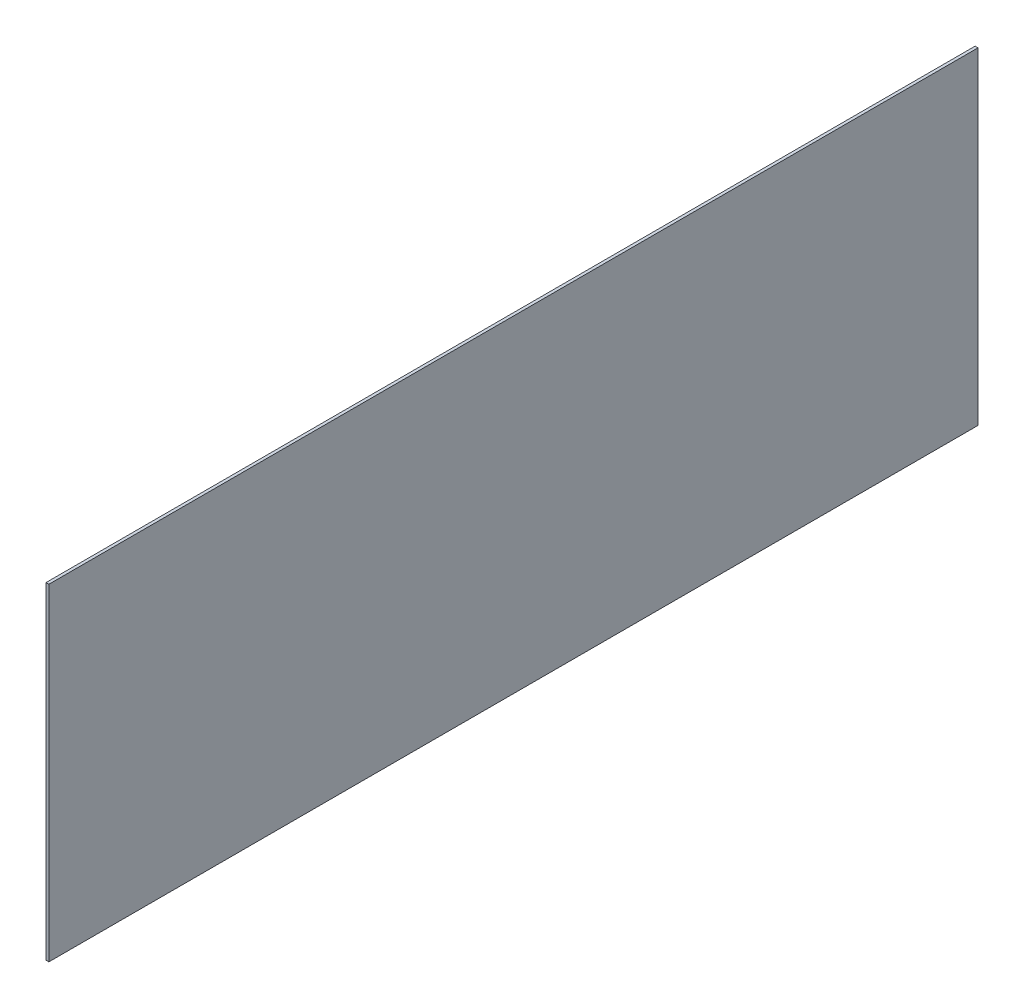
from build123d import *

# Parameters (mm, degrees)
SKETCH1_W           = 508
SKETCH1_H           = 178.816
BOSS_EXTRUDE1_DEPTH = 1.5875


with BuildPart() as part:
    # Sketch1 → Boss-Extrude1 (new body)
    with BuildSketch(Plane(origin=(0, 0, 0), x_dir=(0, 0, -1), z_dir=(1, 0, 0))):
        Rectangle(SKETCH1_W, SKETCH1_H)
    extrude(amount=BOSS_EXTRUDE1_DEPTH)


solid = part.part
